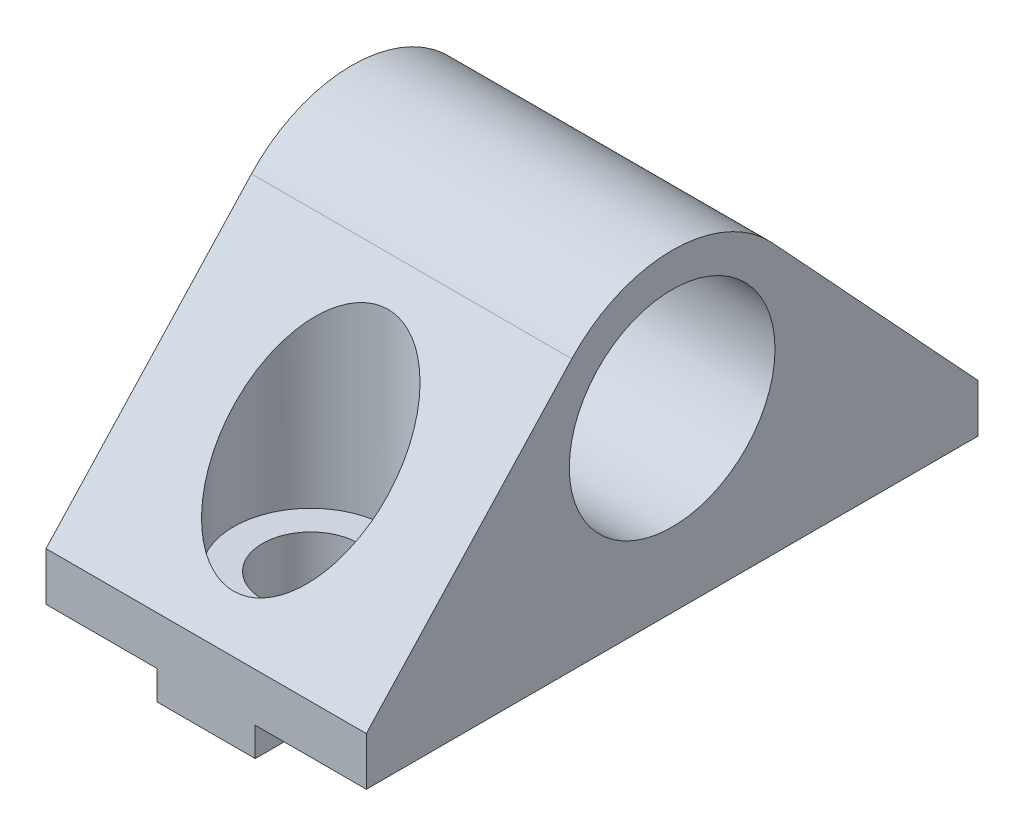
from build123d import *

# Parameters (mm, degrees)
BOSS_EXTRUDE1_DEPTH = 38
SKETCH2_R           = 6.39
BOSS_EXTRUDE2_DEPTH = 19.9


with BuildPart() as part:
    # Sketch1 → Boss-Extrude1 (new body)
    with BuildSketch(Plane.XY):
        Polygon((101.60617691, 195.484265545), (108.51617691, 195.484265545), (108.51617691, 193.684265545), (114.604851948, 193.684265545), (114.604851948, 195.484265545), (121.50617691, 195.484265545), (121.50617691, 198.484265545), (101.60617691, 198.484265545), align=None)
    extrude(amount=-BOSS_EXTRUDE1_DEPTH)

    # Sketch2 → Boss-Extrude2 (add)
    with BuildSketch(Plane.ZY.offset(-101.60617691)):
        with BuildLine():
            Line((-38, 198.484265545), (-25.235062395, 212.261288734))
            ThreePointArc((-25.235062395, 212.261288734), (-19, 214.984265545), (-12.764937605, 212.261288734))
            Line((-12.764937605, 212.261288734), (0, 198.484265545))
            Line((0, 198.484265545), (-38, 198.484265545))
        make_face()
        with Locations((-19, 206.484265545)):
            Circle(SKETCH2_R, mode=Mode.SUBTRACT)
    extrude(amount=-BOSS_EXTRUDE2_DEPTH)

    # Sketch3 → Cut-Revolve1 (revolve, cut)
    with BuildSketch(Plane.ZY.offset(-111.55617691)):
        Polygon((-26.7, 211.670017018), (-26.7, 198.985665545), (-28.5, 198.985665545), (-28.5, 189.906068288), (-31.5, 189.906068288), (-31.5, 211.670017018), align=None)
    cut_revolve1 = revolve(axis=Axis((111.55617691, 189.906068288, -31.5), (0, 1, 0)), mode=Mode.SUBTRACT)

    # Mirror1: Cut-Revolve1 across plane
    add(cut_revolve1.mirror(Plane(origin=(0, 0, -19), x_dir=(1, 0, 0), z_dir=(0, 0, -1))), mode=Mode.SUBTRACT)


solid = part.part
